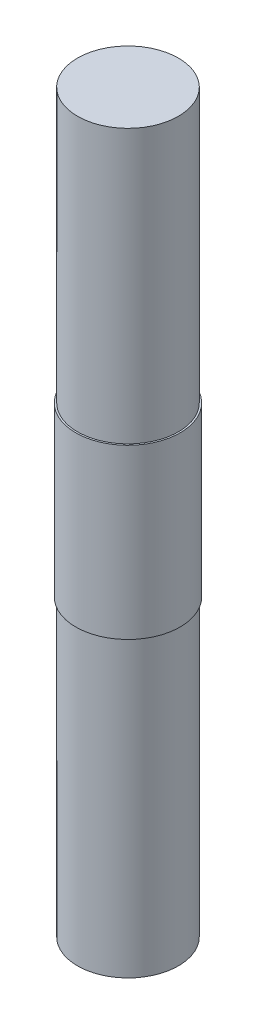
from build123d import *


with BuildPart() as part:
    # Sketch1 → Revolve4 (revolve)
    with BuildSketch(Plane.XY):
        Polygon((0, 0), (0, -52.5), (0, -87.5), (6, -87.5), (6, -52.5), (6.2, -52.5), (6.2, -32.5), (6, -32.5), (6, -30), (6, 0), align=None)
    revolve(axis=Axis((0, 0, 0), (0, -1, 0)))


solid = part.part
